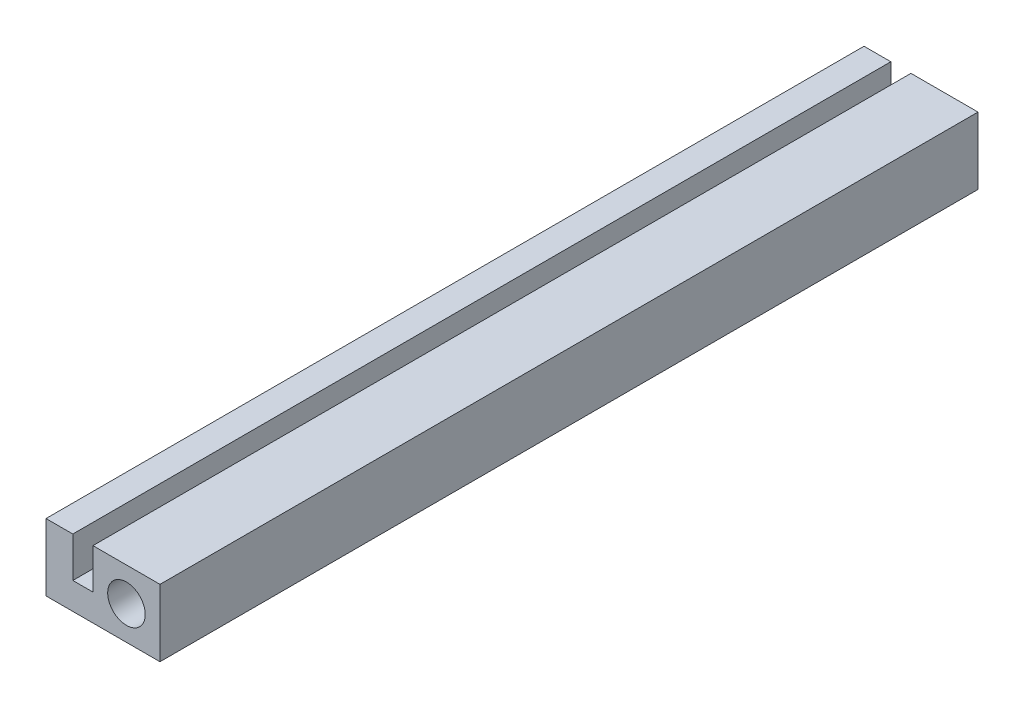
from build123d import *

# Parameters (mm, degrees)
ESQUISSE1_R        = 2.8
BOSS_EXTRU_1_DEPTH = 122


with BuildPart() as part:
    # Esquisse1 → Boss.-Extru.1 (new body)
    with BuildSketch(Plane.XY):
        Polygon((-6.67673977, 2.937050112), (-6.67673977, -7.062949888), (10.32326023, -7.062949888), (10.32326023, 2.937050112), (0.32326023, 2.937050112), (0.32326023, -3.062949888), (-2.67673977, -3.062949888), (-2.67673977, 2.937050112), align=None)
        with Locations((5.32326023, -2.062949888)):
            Circle(ESQUISSE1_R, mode=Mode.SUBTRACT)
    extrude(amount=BOSS_EXTRU_1_DEPTH)


solid = part.part
